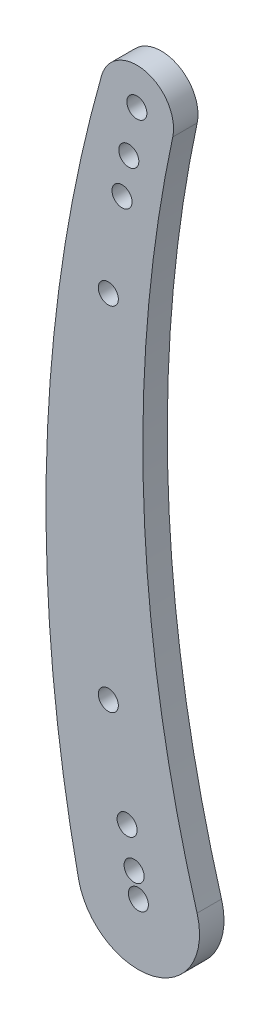
from build123d import *

# Parameters (mm, degrees)
SCHIZZO1_R                   = 2.05
ESTRUSIONE_ESTRUSIONE1_DEPTH = 5
TAGLIO_ESTRUSIONE1_REACH     = 7
SCHIZZO2_R                   = 2.05
SKETCH1_R                    = 2.05
CUT_EXTRUDE1_DEPTH           = 5
CUT_EXTRUDE2_REACH           = 7
SKETCH2_R                    = 2.05


with BuildPart() as part:
    # Schizzo1 → Estrusione-Estrusione1 (new body)
    with BuildSketch(Plane.XY):
        with BuildLine():
            ThreePointArc((7.023974797, 138.427683332), (1.499753731, 147.278176914), (-7.525391936, 142.044153534))
            ThreePointArc((-7.525391936, 142.044153534), (-18.729107246, 69.99949188), (-12.22229981, -2.620188418))
            ThreePointArc((-12.22229981, -2.620188418), (3.068449146, -12.117533571), (11.996332959, 3.512548298))
            ThreePointArc((11.996332959, 3.512548298), (1.102237583, 70.660238267), (7.023974797, 138.427683332))
        make_face()
        Circle(SCHIZZO1_R, mode=Mode.SUBTRACT)
        with Locations((-0.309434746, 139.999658036)):
            Circle(SCHIZZO1_R, mode=Mode.SUBTRACT)
    extrude(amount=ESTRUSIONE_ESTRUSIONE1_DEPTH)

    # Schizzo2 → Taglio-Estrusione1 (cut, up to next)
    with BuildSketch(Plane.XY.offset(5), mode=Mode.PRIVATE) as taglio_estrusione1_sk1:
        with Locations((-6.142115432, 104.166670735)):
            Circle(SCHIZZO2_R)
    taglio_estrusione1_tool1 = extrude(taglio_estrusione1_sk1.sketch, amount=-TAGLIO_ESTRUSIONE1_REACH, mode=Mode.PRIVATE) & part.part
    add(taglio_estrusione1_tool1.solids().sort_by_distance((-6.142115, 104.166671, 5))[0], mode=Mode.SUBTRACT)
    # Schizzo2 → Taglio-Estrusione1 (cut, up to next)
    with BuildSketch(Plane.XY.offset(5), mode=Mode.PRIVATE) as taglio_estrusione1_sk2:
        with Locations((-6.142115432, 32.213749463)):
            Circle(SCHIZZO2_R)
    taglio_estrusione1_tool2 = extrude(taglio_estrusione1_sk2.sketch, amount=-TAGLIO_ESTRUSIONE1_REACH, mode=Mode.PRIVATE) & part.part
    add(taglio_estrusione1_tool2.solids().sort_by_distance((-6.142115, 32.213749, 5))[0], mode=Mode.SUBTRACT)

    # Sketch1 → Cut-Extrude1 (cut)
    with BuildSketch(Plane.XY.offset(5)):
        with Locations((-0.309434746, 139.999658036)):
            Circle(SKETCH1_R)
        with Locations((-1.959092434, 130.643984382)):
            Circle(SKETCH1_R)
        with Locations((-3.348277855, 122.765522358)):
            Circle(SKETCH1_R)
    extrude(amount=-CUT_EXTRUDE1_DEPTH, mode=Mode.SUBTRACT)

    # Sketch2 → Cut-Extrude2 (cut, up to next)
    with BuildSketch(Plane.XY.offset(5), mode=Mode.PRIVATE) as cut_extrude2_sk1:
        with Locations((-0.872956087, 4.578420741)):
            Circle(SKETCH2_R)
    cut_extrude2_tool1 = extrude(cut_extrude2_sk1.sketch, amount=-CUT_EXTRUDE2_REACH, mode=Mode.PRIVATE) & part.part
    add(cut_extrude2_tool1.solids().sort_by_distance((-0.872956, 4.578421, 5))[0], mode=Mode.SUBTRACT)
    # Sketch2 → Cut-Extrude2 (cut, up to next)
    with BuildSketch(Plane.XY.offset(5), mode=Mode.PRIVATE) as cut_extrude2_sk2:
        with Locations((-2.300132251, 12.063577265)):
            Circle(SKETCH2_R)
    cut_extrude2_tool2 = extrude(cut_extrude2_sk2.sketch, amount=-CUT_EXTRUDE2_REACH, mode=Mode.PRIVATE) & part.part
    add(cut_extrude2_tool2.solids().sort_by_distance((-2.300132, 12.063577, 5))[0], mode=Mode.SUBTRACT)


solid = part.part
